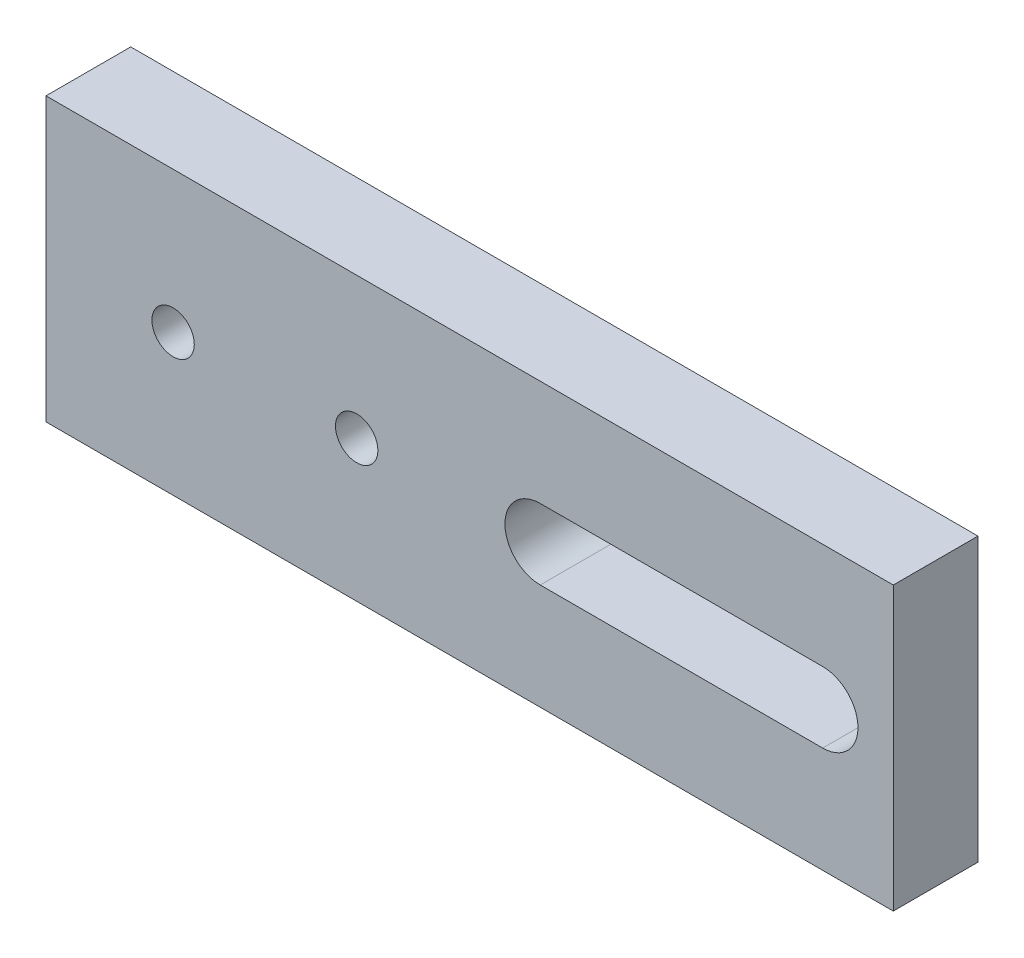
from build123d import *

# Parameters (mm, degrees)
SKETCH1_W           = 60
SKETCH1_H           = 20
SKETCH1_R           = 1.5
BOSS_EXTRUDE1_DEPTH = 6


with BuildPart() as part:
    # Sketch1 → Boss-Extrude1 (new body)
    with BuildSketch(Plane.XY):
        with Locations((30, 10)):
            Rectangle(SKETCH1_W, SKETCH1_H)
        with Locations((22, 10)):
            Circle(SKETCH1_R, mode=Mode.SUBTRACT)
        with Locations((9, 10)):
            Circle(SKETCH1_R, mode=Mode.SUBTRACT)
        with BuildLine():
            Line((35, 12.5), (55, 12.5))
            ThreePointArc((55, 12.5), (57.5, 10), (55, 7.5))
            Line((55, 7.5), (35, 7.5))
            ThreePointArc((35, 7.5), (32.5, 10), (35, 12.5))
        make_face(mode=Mode.SUBTRACT)
    extrude(amount=BOSS_EXTRUDE1_DEPTH)


solid = part.part
